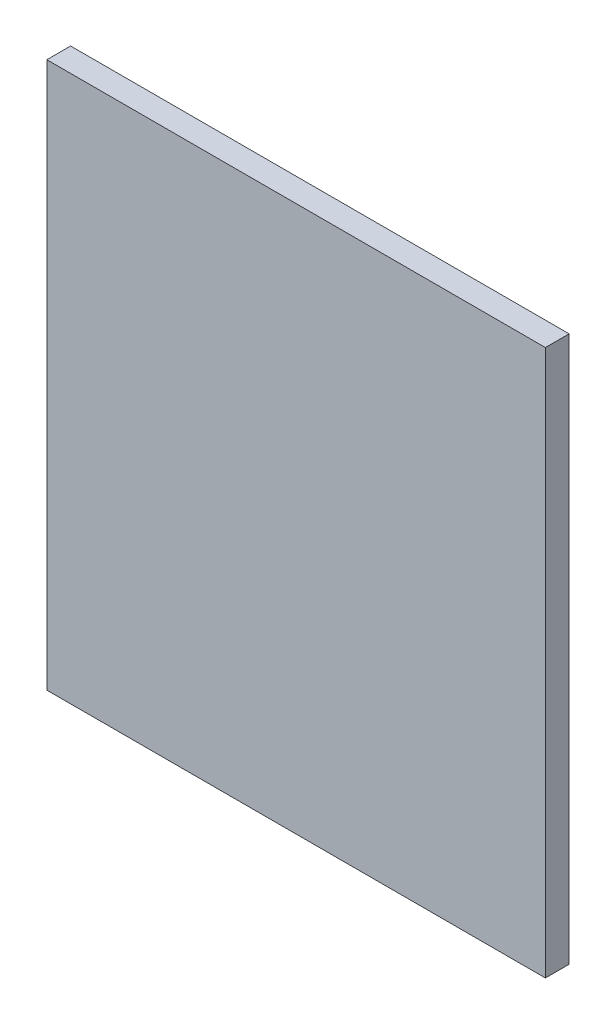
from build123d import *

# Parameters (mm, degrees)
SKETCH2_W           = 266.7
SKETCH2_H           = 292.1
BOSS_EXTRUDE1_DEPTH = 6.35


with BuildPart() as part:
    # Sketch2 → Boss-Extrude1 (new body, symmetric)
    with BuildSketch(Plane.XY):
        Rectangle(SKETCH2_W, SKETCH2_H)
    extrude(amount=BOSS_EXTRUDE1_DEPTH, both=True)


solid = part.part
